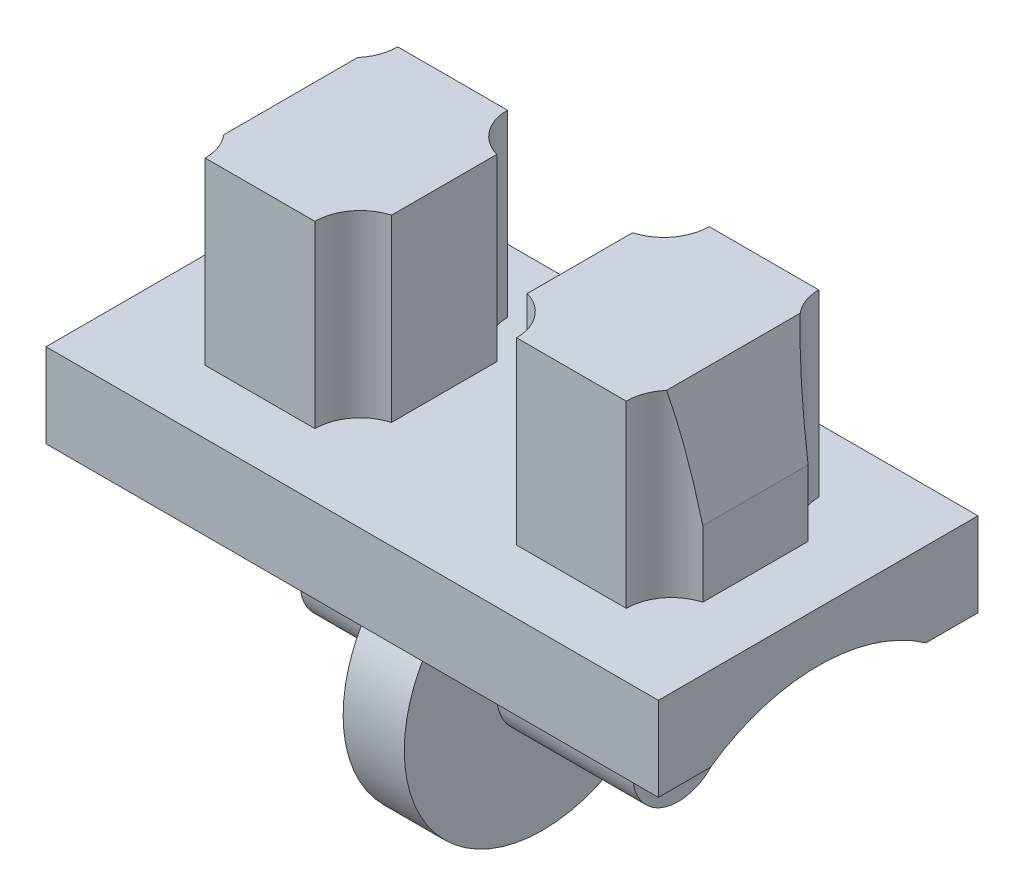
from build123d import *

# Parameters (mm, degrees)
SKETCH1_R           = 1.155
BOSS_EXTRUDE1_DEPTH = 4.215
SKETCH1_3_R         = 1.155
BOSS_EXTRUDE2_DEPTH = 0.775
BOSS_EXTRUDE3_DEPTH = 7.76
BOSS_EXTRUDE4_DEPTH = 4.55
CHAMFER1_SIZE       = 2.87
CHAMFER1_SIZE2      = 0.56


with BuildPart() as part:
    # Sketch1 → Boss-Extrude1 (new body)
    with BuildSketch(Plane(origin=(0, 0, 0), x_dir=(0, 0, -1), z_dir=(1, 0, 0))):
        Circle(SKETCH1_R)
    extrude(amount=BOSS_EXTRUDE1_DEPTH)

    # Sketch1_3 → Boss-Extrude2 (add)
    with BuildSketch(Plane(origin=(0, 0, 0), x_dir=(0, 0, -1), z_dir=(1, 0, 0))):
        with BuildLine():
            ThreePointArc((2.73, 2.737106893), (0, 3.6), (-2.73, 2.737106893))
            Line((-2.73, 2.737106893), (-2.73, 2.198209499))
            ThreePointArc((-2.73, 2.198209499), (0, -3.505), (2.73, 2.198209499))
            Line((2.73, 2.198209499), (2.73, 2.737106893))
        make_face()
        Circle(SKETCH1_3_R, mode=Mode.SUBTRACT)
    extrude(amount=BOSS_EXTRUDE2_DEPTH)

    # Sketch1_4 → Boss-Extrude3 (add)
    with BuildSketch(Plane(origin=(0, 0, 0), x_dir=(0, 0, -1), z_dir=(1, 0, 0))):
        with BuildLine():
            ThreePointArc((-2.73, 2.737106893), (0, 3.6), (2.73, 2.737106893))
            Line((2.73, 2.737106893), (4.05, 2.737106893))
            Line((4.05, 2.737106893), (4.05, 4.867106893))
            Line((4.05, 4.867106893), (-4.05, 4.867106893))
            Line((-4.05, 4.867106893), (-4.05, 2.737106893))
            Line((-4.05, 2.737106893), (-2.73, 2.737106893))
        make_face()
    extrude(amount=BOSS_EXTRUDE3_DEPTH)

    # Sketch2 → Boss-Extrude4 (add)
    with BuildSketch(Plane(origin=(0, 4.867106893, 0), x_dir=(1, 0, 0), z_dir=(0, 1, 0))):
        with BuildLine():
            Line((1.72, -1.333982369), (1.72, 1.333982369))
            ThreePointArc((1.72, 1.333982369), (2.322809893, 1.747089472), (2.555, 2.44))
            Line((2.555, 2.44), (5.335, 2.44))
            ThreePointArc((5.335, 2.44), (5.567190107, 1.747089472), (6.17, 1.333982369))
            Line((6.17, 1.333982369), (6.17, -1.333982369))
            ThreePointArc((6.17, -1.333982369), (5.567190107, -1.747089472), (5.335, -2.44))
            Line((5.335, -2.44), (2.555, -2.44))
            ThreePointArc((2.555, -2.44), (2.322809893, -1.747089472), (1.72, -1.333982369))
        make_face()
    extrude(amount=BOSS_EXTRUDE4_DEPTH)

    # Chamfer1
    chamfer1_edges = [part.edges().sort_by_distance(p)[0] for p in [
        (6.17, 9.417106893, 0),
    ]]
    chamfer1_side = [part.faces().sort_by_distance(p)[0] for p in [
        (6.17, 7.142106893, 0),
    ]]
    chamfer(chamfer1_edges, length=CHAMFER1_SIZE, length2=CHAMFER1_SIZE2, reference=chamfer1_side[0])

    # Mirror1: part across plane


with BuildPart() as part_1:
    add(part.part)
    add(part.part.mirror(Plane(origin=(0, 0, 0), x_dir=(0, 0, 1), z_dir=(1, 0, 0))))


solid = part_1.part
